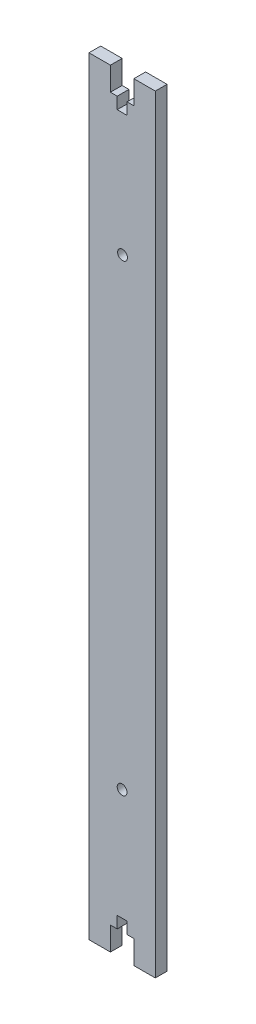
from build123d import *

# Parameters (mm, degrees)
SKETCH1_W           = 28.28
SKETCH1_H           = 327.5
BOSS_EXTRUDE1_DEPTH = 5
SKETCH2_R           = 2.1
CUT_EXTRUDE1_DEPTH  = 10
SKETCH3_R           = 2.1
CUT_EXTRUDE2_DEPTH  = 10


with BuildPart() as part:
    # Sketch1 → Boss-Extrude1 (new body)
    with BuildSketch(Plane.XY):
        Rectangle(SKETCH1_W, SKETCH1_H)
    extrude(amount=BOSS_EXTRUDE1_DEPTH)

    # Sketch2 → Cut-Extrude1 (cut)
    with BuildSketch(Plane.XY.offset(5)):
        with Locations((0.1639809, 96.25)):
            Circle(SKETCH2_R)
        Polygon((5, 163.75), (5, 153.75), (2.1, 153.75), (2.1, 148.75), (-2.1, 148.75), (-2.1, 153.75), (-5, 153.75), (-5, 163.75), align=None)
        Polygon((-5, -163.75), (-5, -153.75), (-2.1, -153.75), (-2.1, -148.75), (2.1, -148.75), (2.1, -153.75), (5, -153.75), (5, -163.75), align=None)
    extrude(amount=-CUT_EXTRUDE1_DEPTH, mode=Mode.SUBTRACT)

    # Sketch3 → Cut-Extrude2 (cut)
    with BuildSketch(Plane.XY.offset(5)):
        with Locations((-0.002135624, -101.25)):
            Circle(SKETCH3_R)
    extrude(amount=-CUT_EXTRUDE2_DEPTH, mode=Mode.SUBTRACT)


solid = part.part
